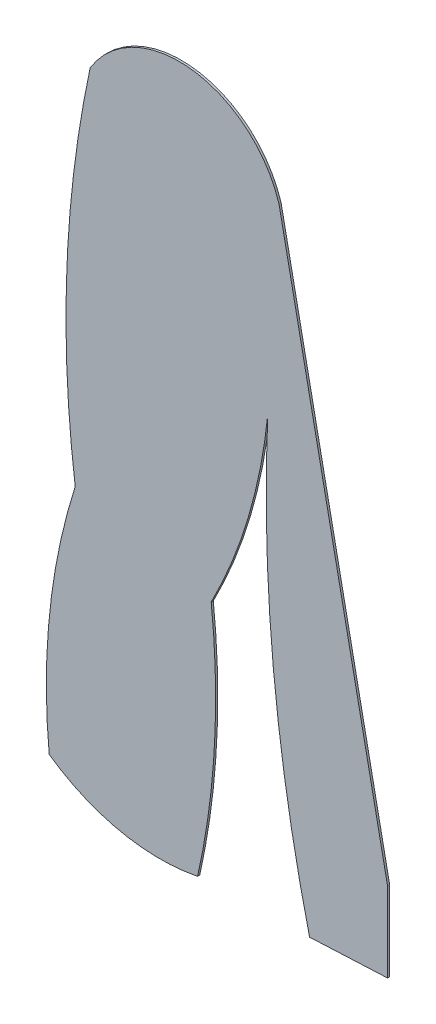
from build123d import *

# Parameters (mm, degrees)
SALIENTE_EXTRUIR1_DEPTH = 0.1


with BuildPart() as part:
    # Model → Saliente-Extruir1 (new body)
    with BuildSketch(Plane.XY):
        with BuildLine():
            Line((14.734818135, -5.091278375), (14.734818135, -1.303795454))
            Line((14.734818135, -1.303795454), (9.586125983, 24.133225595))
            ThreePointArc((9.586125983, 24.133225595), (5.468112004, 27.581522666), (0.631193944, 25.246353401))
            ThreePointArc((0.631193944, 25.246353401), (-0.474240962, 16.497831322), (-0.079037247, 7.688606673))
            ThreePointArc((-0.079037247, 7.688606673), (-1.286055473, 1.941103292), (-1.312470922, -3.931714629))
            ThreePointArc((-1.312470922, -3.931714629), (2.054115678, -5.399292803), (5.726611642, -5.420843381))
            ThreePointArc((5.726611642, -5.420843381), (6.52637867, 0.347218865), (6.371178308, 6.168394193))
            ThreePointArc((6.371178308, 6.168394193), (8.138725842, 10.560479173), (9.052593122, 15.205851208))
            ThreePointArc((9.052593122, 15.205851208), (9.320849308, 4.901113732), (11.037087709, -5.263240729))
            Line((11.037087709, -5.263240729), (14.734818135, -5.091278375))
        make_face()
    extrude(amount=SALIENTE_EXTRUIR1_DEPTH)


solid = part.part
